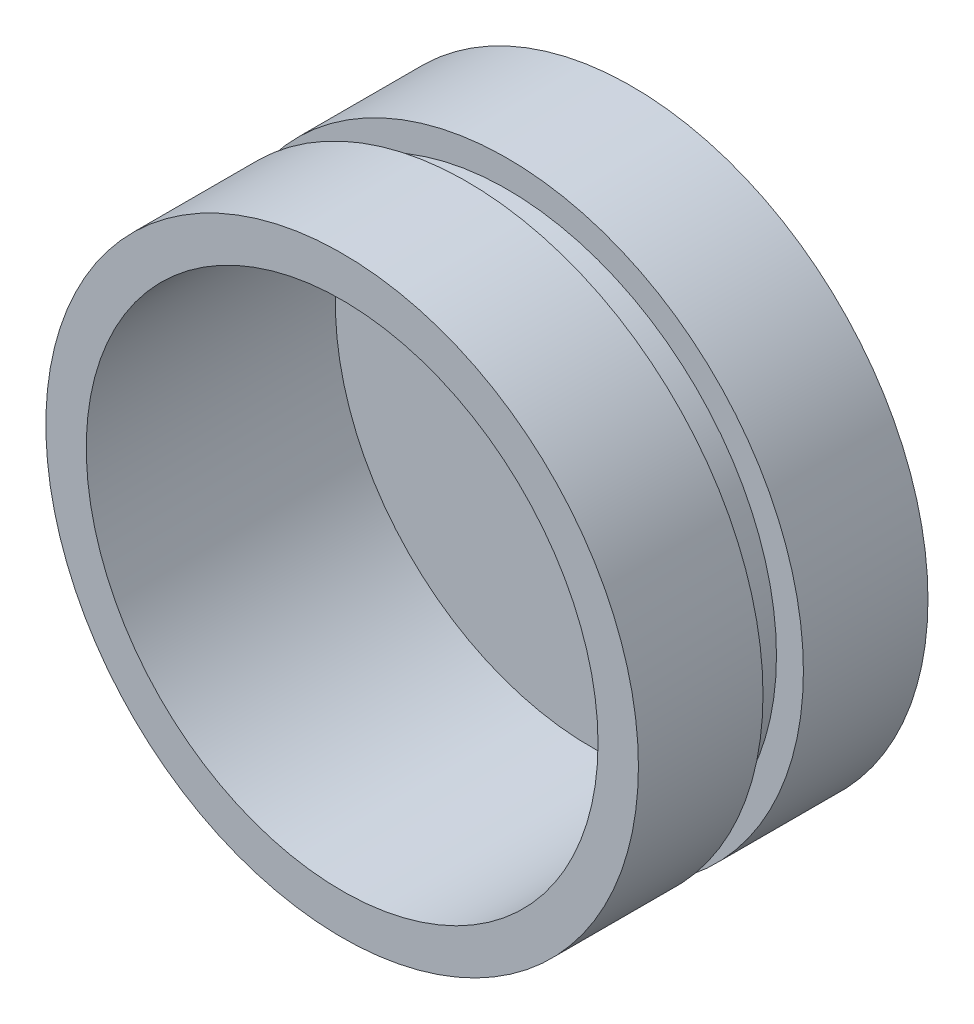
from build123d import *

# Parameters (mm, degrees)
SKETCH1_R           = 22
SKETCH1_R_2         = 2
BOSS_EXTRUDE1_DEPTH = 21.5
SKETCH2_R           = 19
CUT_EXTRUDE1_DEPTH  = 18.5
SKETCH3_R           = 22
SKETCH3_R_2         = 20
CUT_EXTRUDE2_DEPTH  = 1.5


with BuildPart() as part:
    # Sketch1 → Boss-Extrude1 (new body)
    with BuildSketch(Plane.XY):
        Circle(SKETCH1_R)
        Circle(SKETCH1_R_2, mode=Mode.SUBTRACT)
    extrude(amount=BOSS_EXTRUDE1_DEPTH)

    # Sketch2 → Cut-Extrude1 (cut)
    with BuildSketch(Plane.XY.offset(21.5)):
        Circle(SKETCH2_R)
    extrude(amount=-CUT_EXTRUDE1_DEPTH, mode=Mode.SUBTRACT)

    # Sketch3 → Cut-Extrude2 (cut, symmetric)
    with BuildSketch(Plane.XY.offset(10.75)):
        Circle(SKETCH3_R)
        Circle(SKETCH3_R_2, mode=Mode.SUBTRACT)
    extrude(amount=CUT_EXTRUDE2_DEPTH, both=True, mode=Mode.SUBTRACT)


solid = part.part
